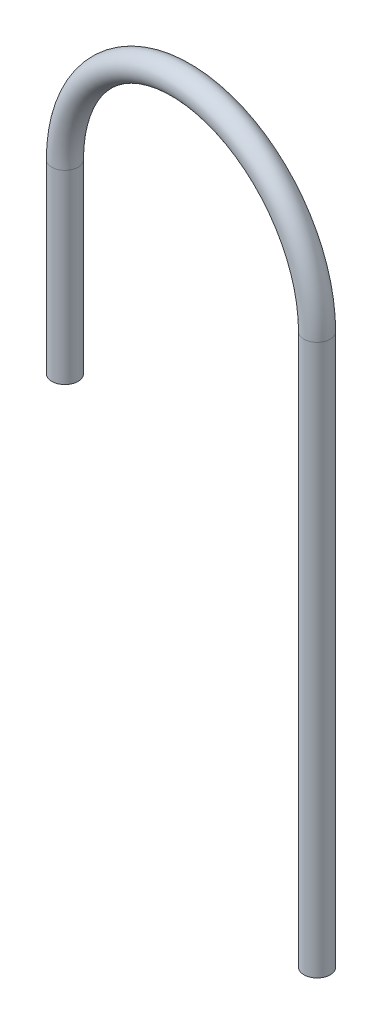
from build123d import *

# Parameters (mm, degrees)
BALAYAGE_MINCE1_PROFILE_R   = 3
BALAYAGE_MINCE1_PROFILE_R_2 = 2


with BuildPart() as part:
    # Balayage-Mince1: sweep along a curve in space
    with BuildLine() as balayage_mince1_path:
        Line((14, 165, -59.25), (14, 207.375, -59.25))
        ThreePointArc((14, 207.375, -59.25), (45.407462351, 238.890799577, -56.639074556), (76.814924701, 207.375, -54.028149113))
        Line((76.814924701, 207.375, -54.028149113), (76.814924701, 81.65, -54.028149113))
    # Balayage-Mince1 profile (on start of the path) → Balayage-Mince1 (sweep)
    with BuildSketch(Plane(origin=(14, 165, -59.25), x_dir=(0, 0, 1), z_dir=(0, 1, 0))):
        Circle(BALAYAGE_MINCE1_PROFILE_R)
        Circle(BALAYAGE_MINCE1_PROFILE_R_2, mode=Mode.SUBTRACT)
    sweep(path=balayage_mince1_path.line)


solid = part.part
